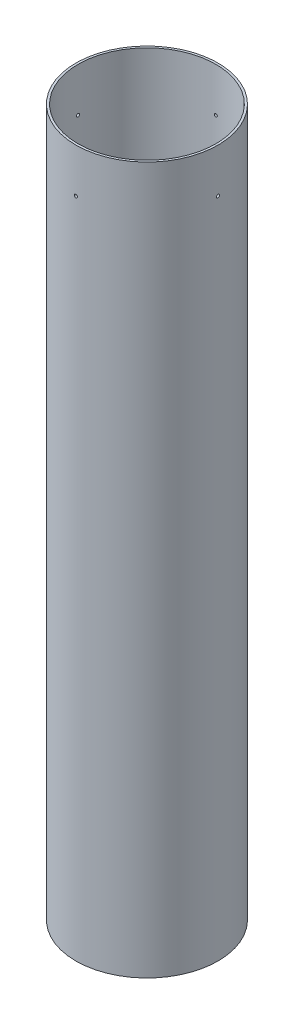
from build123d import *

# Parameters (mm, degrees)
SKETCH1_R           = 51.1048
SKETCH1_R_2         = 49.53
BOSS_EXTRUDE1_DEPTH = 508
SKETCH2_R           = 1.0922
CUT_EXTRUDE1_DEPTH  = 52.1048
CIRPATTERN2_COUNT   = 4


with BuildPart() as part:
    # Sketch1 → Boss-Extrude1 (new body)
    with BuildSketch(Plane(origin=(0, 0, 0), x_dir=(1, 0, 0), z_dir=(0, 1, 0))):
        Circle(SKETCH1_R)
        Circle(SKETCH1_R_2, mode=Mode.SUBTRACT)
    extrude(amount=BOSS_EXTRUDE1_DEPTH)

    # Sketch2 → Cut-Extrude1 (cut, through all)
    with BuildSketch(Plane.XY):
        with Locations((0, 476.25)):
            Circle(SKETCH2_R)
    cut_extrude1 = extrude(amount=-CUT_EXTRUDE1_DEPTH, mode=Mode.SUBTRACT)

    # CirPattern2: Cut-Extrude1 ×4 about axis
    cirpattern2_axis = Axis((0, 508, 0), (0, -1, 0))
    for i in range(1, CIRPATTERN2_COUNT):
        add(cut_extrude1.rotate(cirpattern2_axis, i * 360 / CIRPATTERN2_COUNT), mode=Mode.SUBTRACT)


solid = part.part
